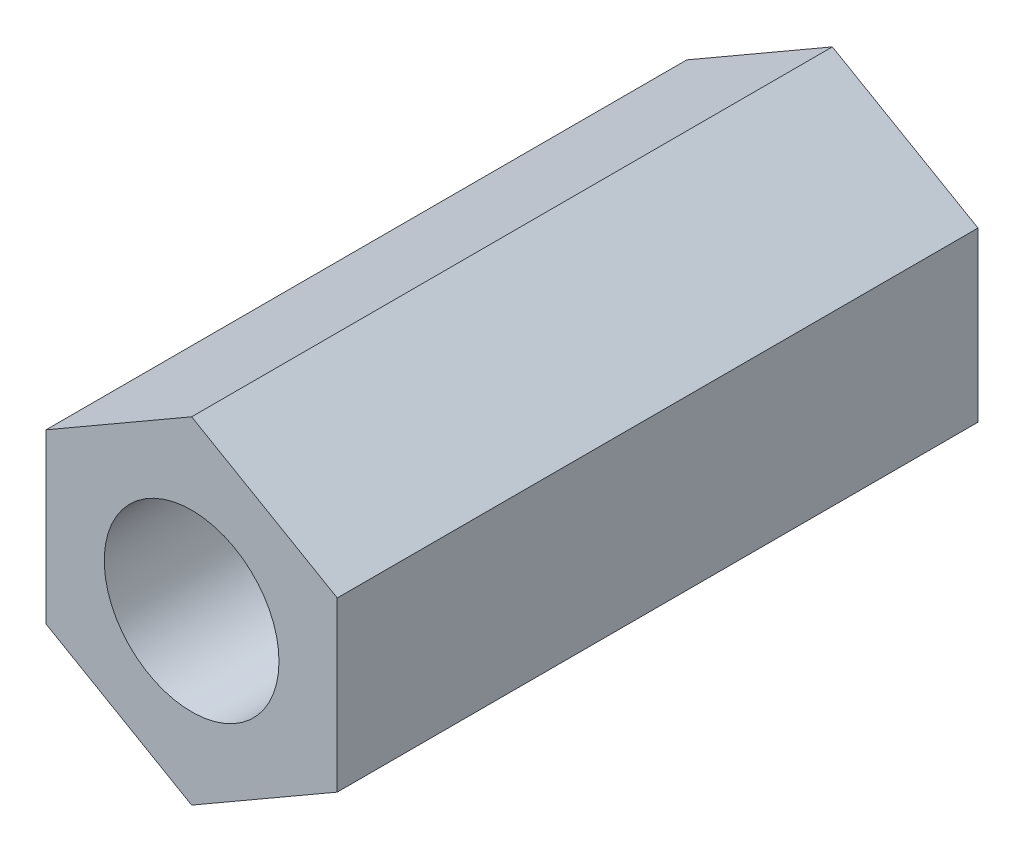
from build123d import *

# Parameters (mm, degrees)
ESQUISSE1_R        = 1.5
BOSS_EXTRU_1_DEPTH = 11


with BuildPart() as part:
    # Esquisse1 → Boss.-Extru.1 (new body)
    with BuildSketch(Plane.XY):
        Polygon((2.5, 1.443375673), (0, 2.886751346), (-2.5, 1.443375673), (-2.5, -1.443375673), (0, -2.886751346), (2.5, -1.443375673), align=None)
        Circle(ESQUISSE1_R, mode=Mode.SUBTRACT)
    extrude(amount=BOSS_EXTRU_1_DEPTH)


solid = part.part
